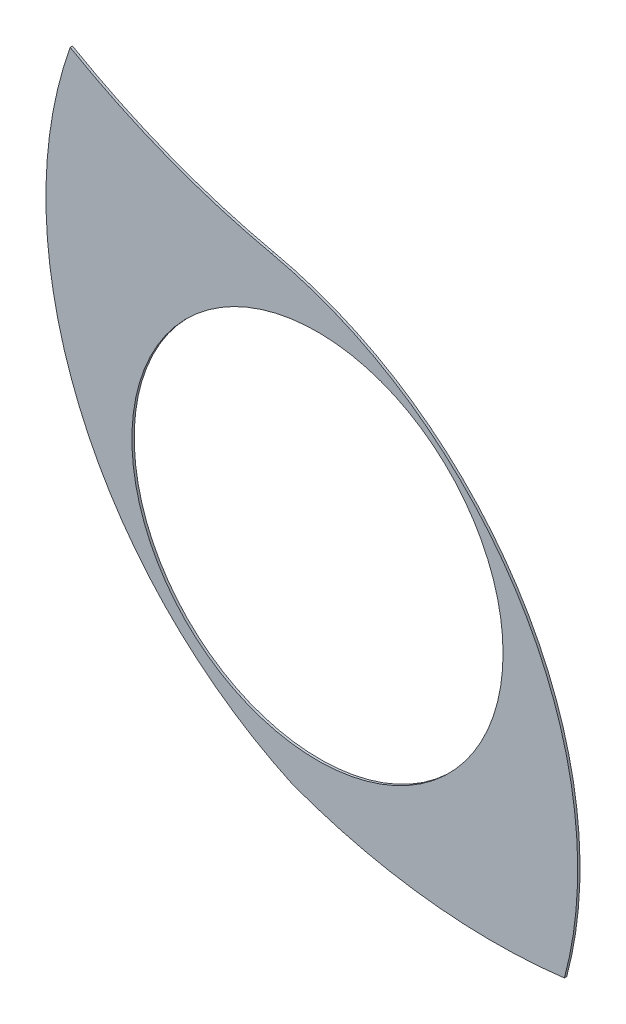
from build123d import *

# Parameters (mm, degrees)
MODEL_R                 = 8
SALIENTE_EXTRUIR1_DEPTH = 0.1


with BuildPart() as part:
    # Model → Saliente-Extruir1 (new body)
    with BuildSketch(Plane.XY):
        with BuildLine():
            ThreePointArc((27.14548024, 7.194414678), (25.273911912, 20.263089859), (14.523964876, 27.926749411))
            ThreePointArc((14.523964876, 27.926749411), (10.054231622, 29.274256382), (5.841127337, 31.28523691))
            ThreePointArc((5.841127337, 31.28523691), (6.23485784, 18.070799585), (15.423765374, 8.566045203))
            ThreePointArc((15.423765374, 8.566045203), (21.202282113, 7.176560753), (27.14548024, 7.194414678))
        make_face()
        with Locations((16.501428973, 17.994891823)):
            Circle(MODEL_R, mode=Mode.SUBTRACT)
    extrude(amount=SALIENTE_EXTRUIR1_DEPTH)


solid = part.part
